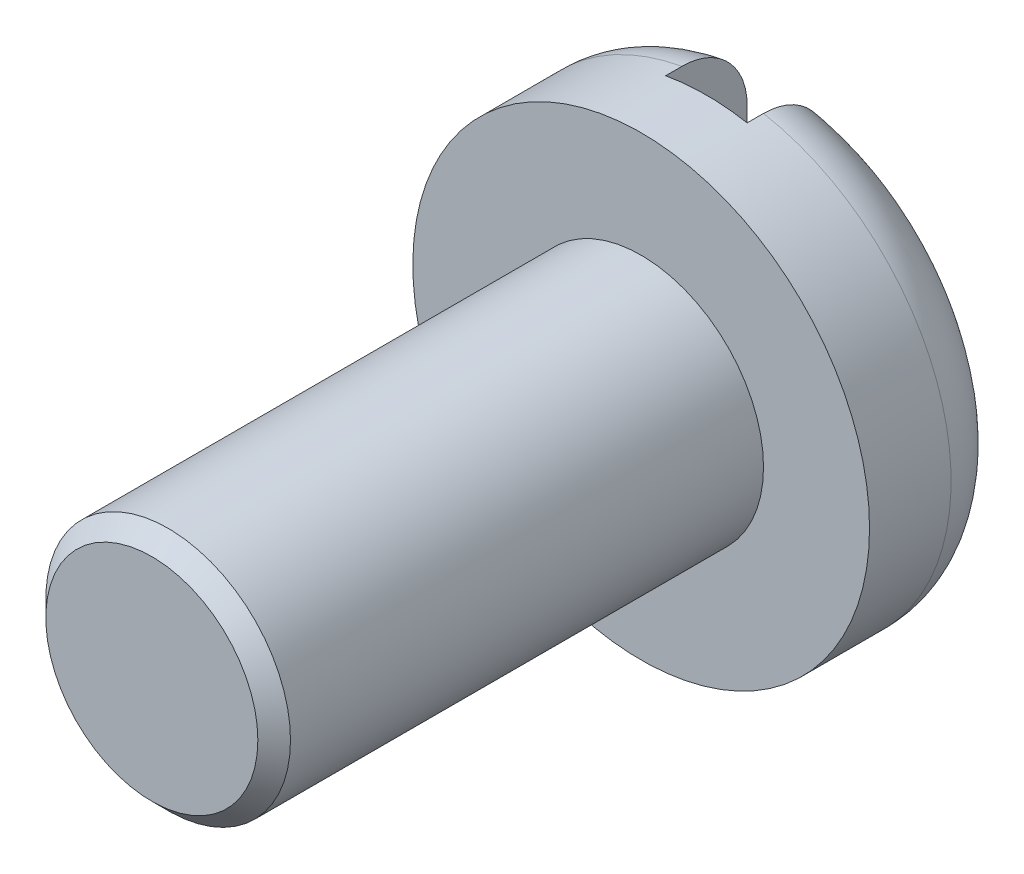
from build123d import *

# Parameters (mm, degrees)
ESQUISSE1_R                  = 2.8
BASE_EXTRUSION_DEPTH         = 1.8
CONG_1_R                     = 0.8
ESQUISSE2_R                  = 1.5
BOSS_EXTRU_1_DEPTH           = 6
CHANFREIN1_SIZE              = 0.2
ESQUISSE3_W                  = 1
ESQUISSE3_H                  = 1
ENL_V_MAT_EXTRU_1_DEPTH      = 3.8000001
ENL_V_MAT_EXTRU_1_DEPTH_BACK = 3.8


with BuildPart() as part:
    # Esquisse1 → Base-Extrusion (new body)
    with BuildSketch(Plane.XY):
        Circle(ESQUISSE1_R)
    extrude(amount=BASE_EXTRUSION_DEPTH)

    # Cong_1
    cong_1_edges = [part.edges().sort_by_distance(p)[0] for p in [
        (-2.8, 0, 0),
    ]]
    fillet(cong_1_edges, radius=CONG_1_R)

    # Esquisse2 → Boss.-Extru.1 (add)
    with BuildSketch(Plane.XY.offset(1.8)):
        Circle(ESQUISSE2_R)
    extrude(amount=BOSS_EXTRU_1_DEPTH)

    # Chanfrein1
    chanfrein1_edges = [part.edges().sort_by_distance(p)[0] for p in [
        (-1.5, 0, 7.8),
    ]]
    chamfer(chanfrein1_edges, length=CHANFREIN1_SIZE)

    # Esquisse3 → Enl_v. mat.-Extru.1 (cut, two sides)
    with BuildSketch(Plane(origin=(0, 0, 0), x_dir=(1, 0, 0), z_dir=(0, 1, 0))) as enl_v_mat_extru_1_sk:
        with Locations((0, -0.5)):
            Rectangle(ESQUISSE3_W, ESQUISSE3_H)
    extrude(amount=ENL_V_MAT_EXTRU_1_DEPTH, mode=Mode.SUBTRACT)
    extrude(enl_v_mat_extru_1_sk.sketch, amount=-ENL_V_MAT_EXTRU_1_DEPTH_BACK, mode=Mode.SUBTRACT)


solid = part.part
